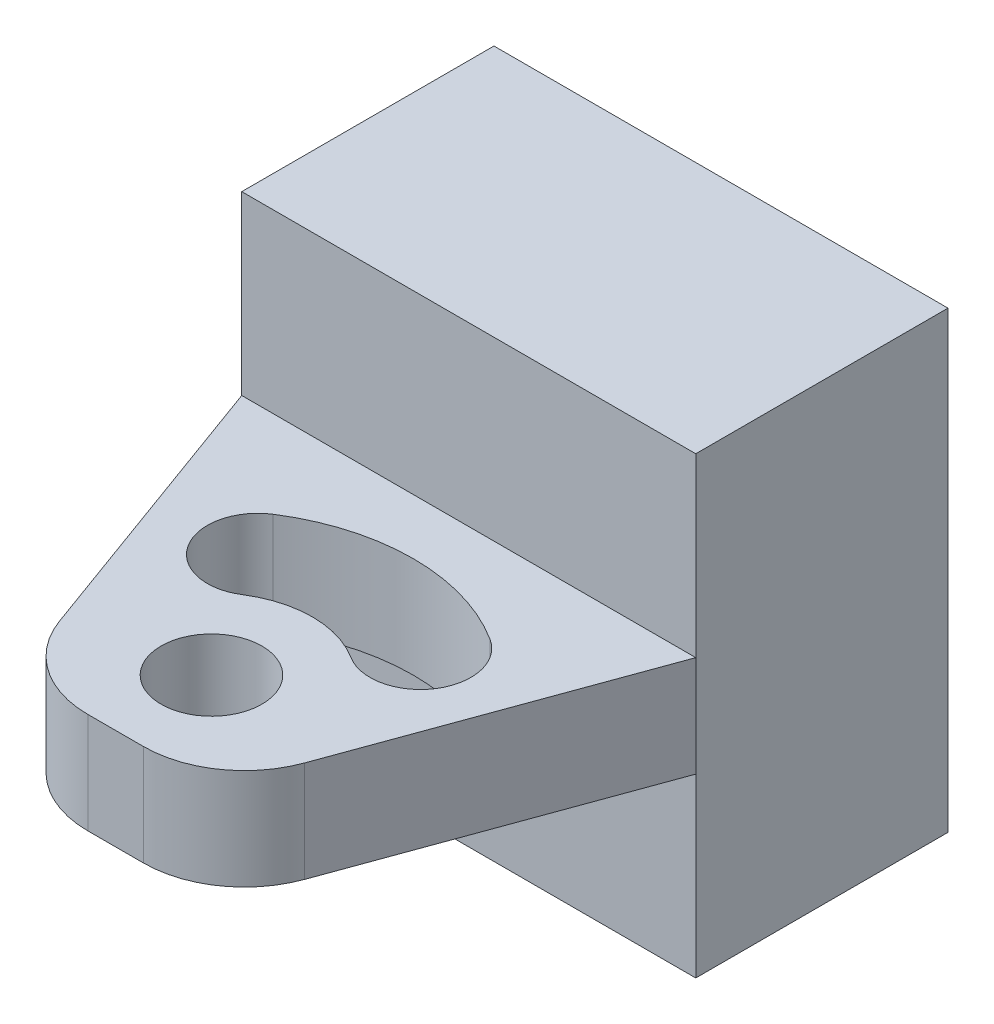
from build123d import *

# Parameters (mm, degrees)
SKETCH1_W           = 45
SKETCH1_H           = 45
BOSS_EXTRUDE1_DEPTH = 25
SKETCH3_W           = 45
SKETCH3_H           = 10
BOSS_EXTRUDE2_DEPTH = 35
SKETCH4_R           = 5
CUT_EXTRUDE4_DEPTH  = 28.5
CUT_EXTRUDE5_DEPTH  = 46
FILLET1_R           = 10


with BuildPart() as part:
    # Sketch1 → Boss-Extrude1 (new body)
    with BuildSketch(Plane.XY):
        with Locations((22.5, 22.5)):
            Rectangle(SKETCH1_W, SKETCH1_H)
    extrude(amount=BOSS_EXTRUDE1_DEPTH)

    # Sketch3 → Boss-Extrude2 (add)
    with BuildSketch(Plane.XY.offset(25)):
        with Locations((22.5, 22.5)):
            Rectangle(SKETCH3_W, SKETCH3_H)
    extrude(amount=BOSS_EXTRUDE2_DEPTH)

    # Sketch4 → Cut-Extrude4 (cut, through all)
    with BuildSketch(Plane.XZ.offset(-17.5)):
        with Locations((22.5, 50.5)):
            Circle(SKETCH4_R)
        with BuildLine():
            ThreePointArc((33.245992167, 33.632171084), (34.776451354, 40.535626355), (27.872996083, 42.066085542))
            ThreePointArc((27.872996083, 42.066085542), (22.5, 40.5), (17.127003917, 42.066085542))
            ThreePointArc((17.127003917, 42.066085542), (10.223548646, 40.535626355), (11.754007833, 33.632171084))
            ThreePointArc((11.754007833, 33.632171084), (22.5, 30.5), (33.245992167, 33.632171084))
        make_face()
    extrude(amount=-CUT_EXTRUDE4_DEPTH, mode=Mode.SUBTRACT)

    # Sketch5 → Cut-Extrude5 (cut, through all)
    with BuildSketch(Plane(origin=(0, 0, 0), x_dir=(1, 0, 0), z_dir=(0, 1, 0))):
        Polygon((45, -25), (32.261041801, -60), (45, -60), align=None)
        Polygon((0, -25), (12.738958199, -60), (0, -60), align=None)
    extrude(amount=CUT_EXTRUDE5_DEPTH, mode=Mode.SUBTRACT)

    # Fillet1
    fillet1_edges = [part.edges().sort_by_distance(p)[0] for p in [
        (12.738958199, 22.5, 60),
        (32.261041801, 22.5, 60),
    ]]
    fillet(fillet1_edges, radius=FILLET1_R)


solid = part.part
